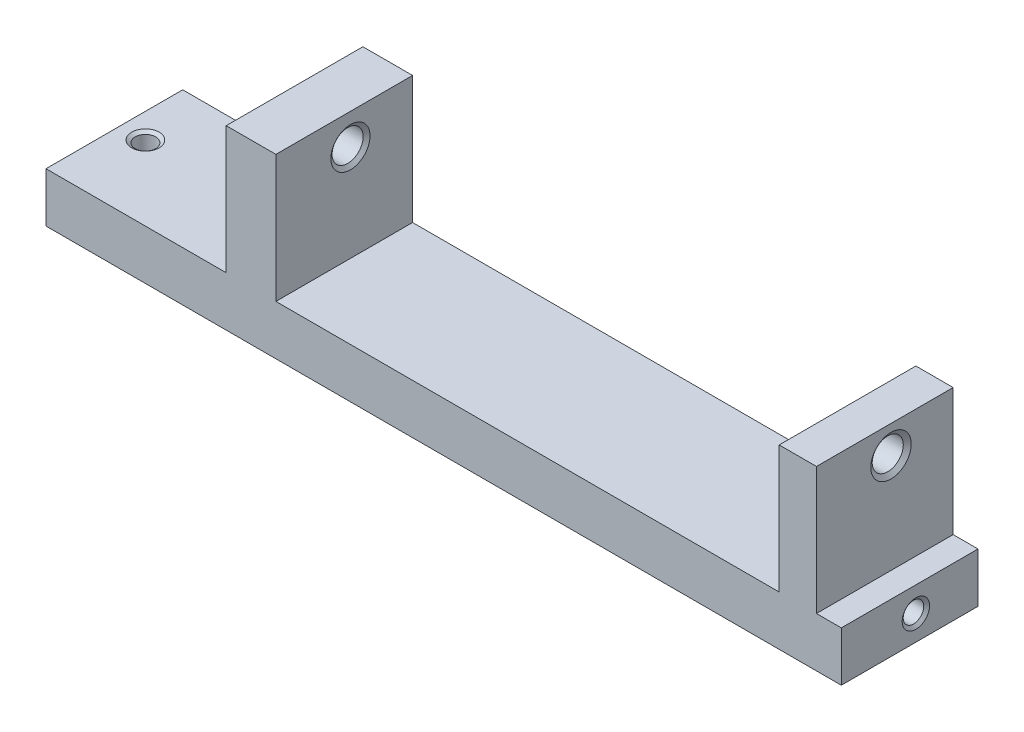
from build123d import *

# Parameters (mm, degrees)
EXTRUDE_1_DEPTH     = 22
M4X0_72_D           = 3.3
M4X0_72_DEPTH       = 11.5
M4X0_72_CSINK_D     = 4.4
M4X0_72_CSINK_ANGLE = 110
M4X0_72_TIP         = 0.991420021


with BuildPart() as part:
    # Эскиз1 → Бобышка-Вытянуть1 (new body)
    with BuildSketch(Plane.XY):
        Polygon((0, 0), (128, 0), (128, 8), (124, 8), (124, 28.5), (118, 28.5), (118, 8), (37, 8), (37, 28.5), (29, 28.5), (29, 8), (0, 8), align=None)
    extrude(amount=EXTRUDE_1_DEPTH)

    # Эскиз2 → Отверстие обработанное метчиком M6x1.01 (revolve, cut)
    with BuildSketch(Plane(origin=(29, 23.5, 10), x_dir=(0, 0, 1), z_dir=(0, 1, 0))):
        Polygon((0, 0), (0, 8), (3.15, 8), (2.5, 7.5448651), (2.5, 0.4551349), (3.15, 0), align=None)
    revolve(axis=Axis((22.65, 23.5, 10), (1, 0, 0)), mode=Mode.SUBTRACT)

    # Эскиз4 → Отверстие обработанное метчиком M6x1.02 (revolve, cut)
    with BuildSketch(Plane(origin=(124, 24, 10), x_dir=(0, 0, -1), z_dir=(0, 1, 0))):
        Polygon((0, 0), (0, 6), (3.25, 6), (2.5, 5.474844346), (2.5, 0.525155654), (3.25, 0), align=None)
    revolve(axis=Axis((130.35, 24, 10), (-1, 0, 0)), mode=Mode.SUBTRACT)

    # Эскиз6 → Отверстие обработанное метчиком M4x0.71 (revolve, cut)
    with BuildSketch(Plane(origin=(4, 0, 10), x_dir=(0, 0, -1), z_dir=(1, 0, 0))):
        Polygon((0, 0), (0, 8), (2.2, 8), (1.65, 7.614885854), (1.65, 0.385114146), (2.2, 0), align=None)
    revolve(axis=Axis((4, -6.35, 10), (0, 1, 0)), mode=Mode.SUBTRACT)

    # Отверстие обработанное метчиком M4x0.72
    with Locations(Plane(origin=(128, 0, 0), x_dir=(0, 0, -1), z_dir=(1, 0, 0))):
        with Locations((-10, 4)):
            CounterSinkHole(M4X0_72_D / 2, M4X0_72_CSINK_D / 2, depth=M4X0_72_DEPTH, counter_sink_angle=M4X0_72_CSINK_ANGLE)
            with Locations((0, 0, -(M4X0_72_DEPTH + M4X0_72_TIP / 2))):  # 118° drill point
                Cone(0, M4X0_72_D / 2, M4X0_72_TIP, mode=Mode.SUBTRACT)


solid = part.part
